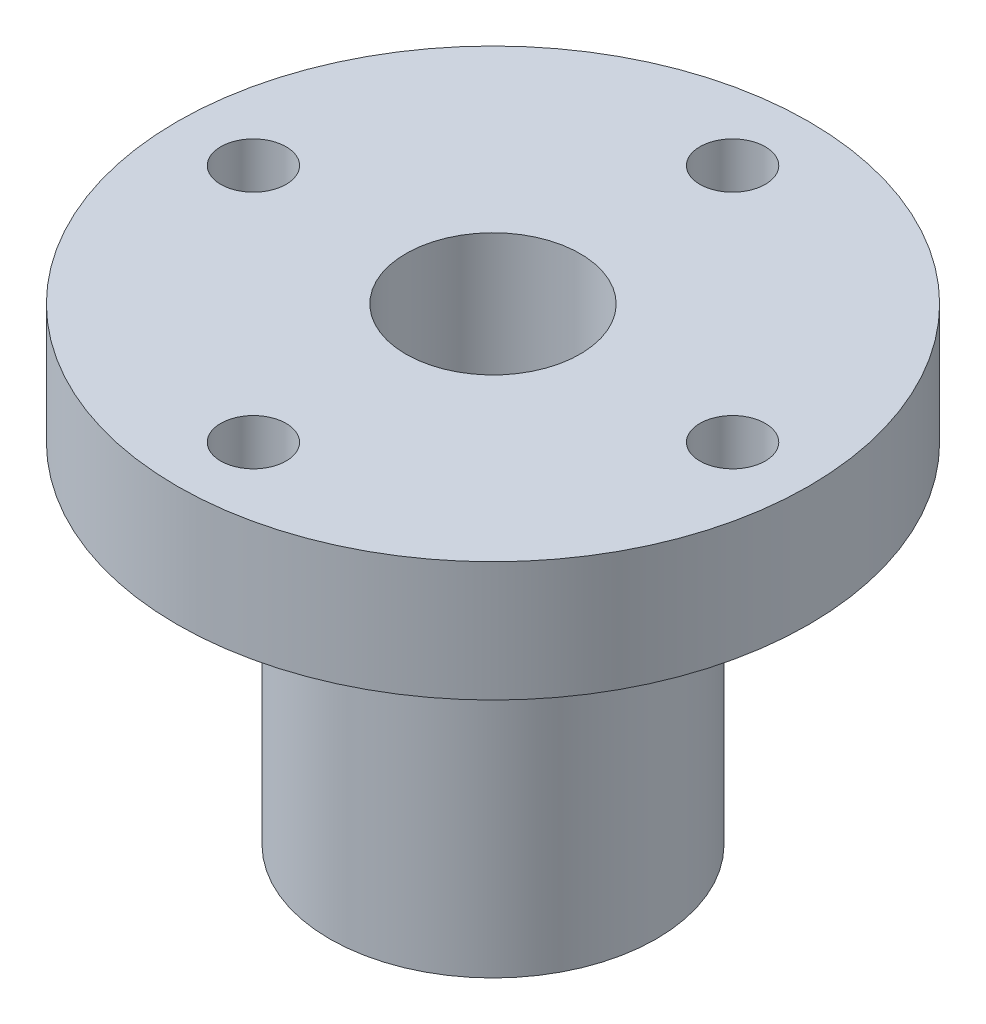
from build123d import *

# Parameters (mm, degrees)
SKETCH1_R           = 7.5
SKETCH1_R_2         = 4
BOSS_EXTRUDE1_DEPTH = 16
SKETCH2_R           = 14.5
SKETCH2_R_2         = 7.5
BOSS_EXTRUDE2_DEPTH = 5.5
SKETCH3_R           = 7.5
SKETCH3_R_2         = 4
BOSS_EXTRUDE3_DEPTH = 5.5
SKETCH4_R           = 1.5
CUT_EXTRUDE1_DEPTH  = 5.5


with BuildPart() as part:
    # Sketch1 → Boss-Extrude1 (new body)
    with BuildSketch(Plane(origin=(0, 0, 0), x_dir=(1, 0, 0), z_dir=(0, 1, 0))):
        Circle(SKETCH1_R)
        Circle(SKETCH1_R_2, mode=Mode.SUBTRACT)
    extrude(amount=BOSS_EXTRUDE1_DEPTH)



with BuildPart() as body_2:
    # Sketch2 → Boss-Extrude2 (new body)
    with BuildSketch(Plane(origin=(0, 16, 0), x_dir=(1, 0, 0), z_dir=(0, 1, 0))):
        Circle(SKETCH2_R)
        Circle(SKETCH2_R_2, mode=Mode.SUBTRACT)
    extrude(amount=BOSS_EXTRUDE2_DEPTH)


with BuildPart() as part_1:
    add(part.part)

    add(body_2.part)  # Boss-Extrude3 merges body 2
    # Sketch3 → Boss-Extrude3 (add)
    with BuildSketch(Plane(origin=(0, 16, 0), x_dir=(1, 0, 0), z_dir=(0, 1, 0))):
        Circle(SKETCH3_R)
        Circle(SKETCH3_R_2, mode=Mode.SUBTRACT)
    extrude(amount=BOSS_EXTRUDE3_DEPTH)

    # Sketch4 → Cut-Extrude1 (cut)
    with BuildSketch(Plane(origin=(0, 21.5, 0), x_dir=(1, 0, 0), z_dir=(0, 1, 0))):
        with Locations((11, 0)):
            Circle(SKETCH4_R)
        with BuildLine():
            ThreePointArc((1.5, -11), (1.060660172, -9.939339828), (0, -9.5))
            Line((0, -9.5), (0, -12.5))
            ThreePointArc((0, -12.5), (1.060660172, -12.060660172), (1.5, -11))
        make_face()
        with BuildLine():
            Line((0, -12.5), (0, -9.5))
            ThreePointArc((0, -9.5), (-1.5, -11), (0, -12.5))
        make_face()
        with Locations((-11, 0)):
            Circle(SKETCH4_R)
        with BuildLine():
            ThreePointArc((1.5, 11), (1.060660172, 12.060660172), (0, 12.5))
            Line((0, 12.5), (0, 9.5))
            ThreePointArc((0, 9.5), (1.060660172, 9.939339828), (1.5, 11))
        make_face()
        with BuildLine():
            Line((0, 9.5), (0, 12.5))
            ThreePointArc((0, 12.5), (-1.5, 11), (0, 9.5))
        make_face()
    extrude(amount=-CUT_EXTRUDE1_DEPTH, mode=Mode.SUBTRACT)


solid = part_1.part
